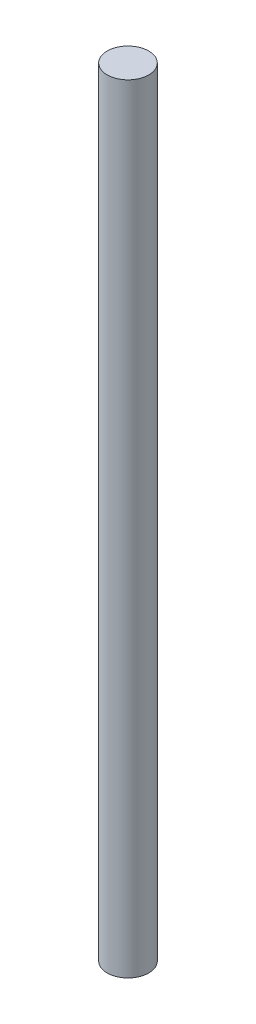
from build123d import *

# Parameters (mm, degrees)
IZIM1_R                     = 8
Y_KSEKLIK_EKSTR_ZYON1_DEPTH = 300


with BuildPart() as part:
    # Çizim1 → Yükseklik-Ekstrüzyon1 (new body)
    with BuildSketch(Plane(origin=(0, 0, 0), x_dir=(1, 0, 0), z_dir=(0, 1, 0))):
        Circle(IZIM1_R)
    extrude(amount=Y_KSEKLIK_EKSTR_ZYON1_DEPTH)


solid = part.part
